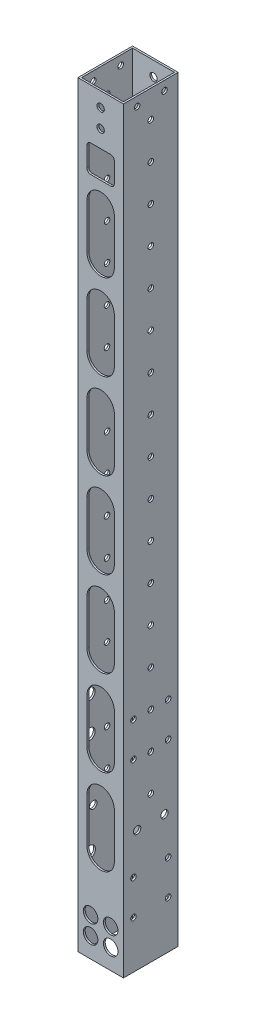
from build123d import *

# Parameters (mm, degrees)
SKETCH_2_W                = 25
SKETCH_2_H                = 30
EXTRUDE_1_DEPTH           = 207.5
SKETCH_3_W                = 23
SKETCH_3_H                = 28
CUT_EXTRUDE_1_DEPTH       = 208.5
CUT_EXTRUDE_1_DEPTH_BACK  = 208.5
SKETCH_4_R                = 1.525
CUT_EXTRUDE_2_DEPTH       = 1
CUT_EXTRUDE_2_DEPTH_BACK  = 26
CUT_EXTRUDE_3_REACH       = 27
SKETCH_5_R                = 3.15
SKETCH_6_R                = 2.025
CUT_EXTRUDE_4_DEPTH       = 31
SKETCH_7_R                = 2.025
CUT_EXTRUDE_5_DEPTH       = 1
CUT_EXTRUDE_5_DEPTH_BACK  = 31
SKETCH_8_R                = 4
CUT_EXTRUDE_6_DEPTH       = 10
SKETCH_9_R                = 1.525
CUT_EXTRUDE_7_DEPTH       = 1
CUT_EXTRUDE_7_DEPTH_BACK  = 26
SKETCH_10_R               = 3
CUT_EXTRUDE_8_DEPTH       = 5
SKETCH_11_R               = 1.525
CUT_EXTRUDE_9_DEPTH       = 26
PATTERN_LINEAR_1_COUNT    = 17
PATTERN_LINEAR_1_PITCH    = 20
SKETCH_13_R               = 1.525
CUT_EXTRUDE_10_DEPTH      = 26
SKETCH_14_R               = 2.025
CUT_EXTRUDE_11_DEPTH      = 1
CUT_EXTRUDE_11_DEPTH_BACK = 26
CUT_EXTRUDE_12_DEPTH      = 5
PATTERN_LINEAR_2_COUNT    = 7
PATTERN_LINEAR_2_PITCH    = 47
CUT_EXTRUDE_13_DEPTH      = 1
CUT_EXTRUDE_13_DEPTH_BACK = 31
CUT_EXTRUDE_14_DEPTH      = 1
CUT_EXTRUDE_14_DEPTH_BACK = 31
CUT_EXTRUDE_15_DEPTH      = 10


with BuildPart() as part:
    # 草图2 → 凸台-拉伸1 (new body, symmetric)
    with BuildSketch(Plane(origin=(0, 0, 0), x_dir=(1, 0, 0), z_dir=(0, 1, 0))):
        Rectangle(SKETCH_2_W, SKETCH_2_H)
    extrude(amount=EXTRUDE_1_DEPTH, both=True)

    # 草图3 → 切除-拉伸1 (cut, two sides)
    with BuildSketch(Plane(origin=(0, 0, 0), x_dir=(1, 0, 0), z_dir=(0, 1, 0))) as cut_extrude_1_sk:
        Rectangle(SKETCH_3_W, SKETCH_3_H)
    extrude(amount=CUT_EXTRUDE_1_DEPTH, mode=Mode.SUBTRACT)
    extrude(cut_extrude_1_sk.sketch, amount=-CUT_EXTRUDE_1_DEPTH_BACK, mode=Mode.SUBTRACT)

    # 草图4 → 切除-拉伸2 (cut, two sides)
    with BuildSketch(Plane.ZY.offset(12.5)) as cut_extrude_2_sk:
        with Locations((-9.5, -162.5)):
            Circle(SKETCH_4_R)
        with Locations((9.5, -162.5)):
            Circle(SKETCH_4_R)
        with Locations((9.5, -181.5)):
            Circle(SKETCH_4_R)
        with Locations((-9.5, -181.5)):
            Circle(SKETCH_4_R)
    extrude(amount=CUT_EXTRUDE_2_DEPTH, mode=Mode.SUBTRACT)
    extrude(cut_extrude_2_sk.sketch, amount=-CUT_EXTRUDE_2_DEPTH_BACK, mode=Mode.SUBTRACT)

    # 草图5 → 切除-拉伸3 (cut, up to next)
    with BuildSketch(Plane.ZY.offset(12.5), mode=Mode.PRIVATE) as cut_extrude_3_sk1:
        with Locations((-9.5, -162.5)):
            Circle(SKETCH_5_R)
    cut_extrude_3_tool1 = extrude(cut_extrude_3_sk1.sketch, amount=-CUT_EXTRUDE_3_REACH, mode=Mode.PRIVATE) & part.part
    add(cut_extrude_3_tool1.solids().sort_by_distance((-12.5, -162.5, -9.5))[0], mode=Mode.SUBTRACT)
    # 草图5 → 切除-拉伸3 (cut, up to next)
    with BuildSketch(Plane.ZY.offset(12.5), mode=Mode.PRIVATE) as cut_extrude_3_sk2:
        with Locations((-9.5, -181.5)):
            Circle(SKETCH_5_R)
    cut_extrude_3_tool2 = extrude(cut_extrude_3_sk2.sketch, amount=-CUT_EXTRUDE_3_REACH, mode=Mode.PRIVATE) & part.part
    add(cut_extrude_3_tool2.solids().sort_by_distance((-12.5, -181.5, -9.5))[0], mode=Mode.SUBTRACT)
    # 草图5 → 切除-拉伸3 (cut, up to next)
    with BuildSketch(Plane.ZY.offset(12.5), mode=Mode.PRIVATE) as cut_extrude_3_sk3:
        with Locations((9.5, -162.5)):
            Circle(SKETCH_5_R)
    cut_extrude_3_tool3 = extrude(cut_extrude_3_sk3.sketch, amount=-CUT_EXTRUDE_3_REACH, mode=Mode.PRIVATE) & part.part
    add(cut_extrude_3_tool3.solids().sort_by_distance((-12.5, -162.5, 9.5))[0], mode=Mode.SUBTRACT)
    # 草图5 → 切除-拉伸3 (cut, up to next)
    with BuildSketch(Plane.ZY.offset(12.5), mode=Mode.PRIVATE) as cut_extrude_3_sk4:
        with Locations((9.5, -181.5)):
            Circle(SKETCH_5_R)
    cut_extrude_3_tool4 = extrude(cut_extrude_3_sk4.sketch, amount=-CUT_EXTRUDE_3_REACH, mode=Mode.PRIVATE) & part.part
    add(cut_extrude_3_tool4.solids().sort_by_distance((-12.5, -181.5, 9.5))[0], mode=Mode.SUBTRACT)

    # 草图6 → 切除-拉伸4 (cut, through all)
    with BuildSketch(Plane(origin=(0, 0, -15), x_dir=(-1, 0, 0), z_dir=(0, 0, -1))):
        with Locations((0, 199.5)):
            Circle(SKETCH_6_R)
        with Locations((0, 189.5)):
            Circle(SKETCH_6_R)
    extrude(amount=-CUT_EXTRUDE_4_DEPTH, mode=Mode.SUBTRACT)

    # 草图7 → 切除-拉伸5 (cut, two sides)
    with BuildSketch(Plane.XY.offset(15)) as cut_extrude_5_sk:
        with Locations((-5.5, -186.5)):
            Circle(SKETCH_7_R)
        with Locations((-5.5, -196.5)):
            Circle(SKETCH_7_R)
        with Locations((5.5, -196.5)):
            Circle(SKETCH_7_R)
        with Locations((5.5, -186.5)):
            Circle(SKETCH_7_R)
    extrude(amount=CUT_EXTRUDE_5_DEPTH, mode=Mode.SUBTRACT)
    extrude(cut_extrude_5_sk.sketch, amount=-CUT_EXTRUDE_5_DEPTH_BACK, mode=Mode.SUBTRACT)

    # 草图8 → 切除-拉伸6 (cut)
    with BuildSketch(Plane.XY.offset(15)):
        with Locations((-5.5, -186.5)):
            Circle(SKETCH_8_R)
        with Locations((5.5, -186.5)):
            Circle(SKETCH_8_R)
        with Locations((5.5, -196.5)):
            Circle(SKETCH_8_R)
        with Locations((-5.5, -196.5)):
            Circle(SKETCH_8_R)
    extrude(amount=-CUT_EXTRUDE_6_DEPTH, mode=Mode.SUBTRACT)

    # 草图9 → 切除-拉伸7 (cut, two sides)
    with BuildSketch(Plane.ZY.offset(12.5)) as cut_extrude_7_sk:
        with Locations((9.5, -106.5)):
            Circle(SKETCH_9_R)
        with Locations((-9.5, -106.5)):
            Circle(SKETCH_9_R)
        with Locations((9.5, -87.5)):
            Circle(SKETCH_9_R)
        with Locations((-9.5, -87.5)):
            Circle(SKETCH_9_R)
    extrude(amount=CUT_EXTRUDE_7_DEPTH, mode=Mode.SUBTRACT)
    extrude(cut_extrude_7_sk.sketch, amount=-CUT_EXTRUDE_7_DEPTH_BACK, mode=Mode.SUBTRACT)

    # 草图10 → 切除-拉伸8 (cut)
    with BuildSketch(Plane.ZY.offset(12.5)):
        with Locations((9.5, -87.5)):
            Circle(SKETCH_10_R)
        with Locations((9.5, -106.5)):
            Circle(SKETCH_10_R)
        with Locations((-9.5, -87.5)):
            Circle(SKETCH_10_R)
        with Locations((-9.5, -106.5)):
            Circle(SKETCH_10_R)
    extrude(amount=-CUT_EXTRUDE_8_DEPTH, mode=Mode.SUBTRACT)

    # 草图11 → 切除-拉伸9 (cut, through all)
    with BuildSketch(Plane.ZY.offset(12.5)):
        with Locations((0, -127.5)):
            Circle(SKETCH_11_R)
    cut_extrude_9 = extrude(amount=-CUT_EXTRUDE_9_DEPTH, mode=Mode.SUBTRACT)

    # 阵列(线性)1: 切除-拉伸9 ×17
    with Locations(*[(0, i * PATTERN_LINEAR_1_PITCH, 0) for i in range(1, PATTERN_LINEAR_1_COUNT)]):
        add(cut_extrude_9, mode=Mode.SUBTRACT)

    # 草图13 → 切除-拉伸10 (cut, through all)
    with BuildSketch(Plane.ZY.offset(12.5)):
        with Locations((7.5, 202.5)):
            Circle(SKETCH_13_R)
        with Locations((-7.5, 202.5)):
            Circle(SKETCH_13_R)
    extrude(amount=-CUT_EXTRUDE_10_DEPTH, mode=Mode.SUBTRACT)

    # 草图14 → 切除-拉伸11 (cut, two sides)
    with BuildSketch(Plane.ZY.offset(12.5)) as cut_extrude_11_sk:
        with Locations((7.5, -141)):
            Circle(SKETCH_14_R)
        with Locations((-7.5, -141)):
            Circle(SKETCH_14_R)
    extrude(amount=CUT_EXTRUDE_11_DEPTH, mode=Mode.SUBTRACT)
    extrude(cut_extrude_11_sk.sketch, amount=-CUT_EXTRUDE_11_DEPTH_BACK, mode=Mode.SUBTRACT)

    # 草图15 → 切除-拉伸12 (cut)
    with BuildSketch(Plane.XY.offset(15)):
        with BuildLine():
            Line((-7.5, -155), (-7.5, -130))
            ThreePointArc((-7.5, -130), (0, -122.5), (7.5, -130))
            Line((7.5, -130), (7.5, -155))
            ThreePointArc((7.5, -155), (0, -162.5), (-7.5, -155))
        make_face()
    cut_extrude_12 = extrude(amount=-CUT_EXTRUDE_12_DEPTH, mode=Mode.SUBTRACT)

    # 阵列(线性)2: 切除-拉伸12 ×7
    with Locations(*[(0, i * PATTERN_LINEAR_2_PITCH, 0) for i in range(1, PATTERN_LINEAR_2_COUNT)]):
        add(cut_extrude_12, mode=Mode.SUBTRACT)

    # 草图17 → 切除-拉伸13 (cut, two sides)
    with BuildSketch(Plane.XY.offset(15)) as cut_extrude_13_sk:
        with BuildLine():
            Line((-5.5, 165), (5.5, 165))
            ThreePointArc((5.5, 165), (6.914213562, 165.585786438), (7.5, 167))
            Line((7.5, 167), (7.5, 178))
            ThreePointArc((7.5, 178), (6.914213562, 179.414213562), (5.5, 180))
            Line((5.5, 180), (-5.5, 180))
            ThreePointArc((-5.5, 180), (-6.914213562, 179.414213562), (-7.5, 178))
            Line((-7.5, 178), (-7.5, 167))
            ThreePointArc((-7.5, 167), (-6.914213562, 165.585786438), (-5.5, 165))
        make_face()
    extrude(amount=CUT_EXTRUDE_13_DEPTH, mode=Mode.SUBTRACT)
    extrude(cut_extrude_13_sk.sketch, amount=-CUT_EXTRUDE_13_DEPTH_BACK, mode=Mode.SUBTRACT)

    # 草图18 → 切除-拉伸14 (cut, two sides)
    with BuildSketch(Plane(origin=(0, 0, -15), x_dir=(-1, 0, 0), z_dir=(0, 0, -1))) as cut_extrude_14_sk:
        with BuildLine():
            Line((-7.5, -155), (-7.5, -130))
            ThreePointArc((-7.5, -130), (0, -122.5), (7.5, -130))
            Line((7.5, -130), (7.5, -155))
            ThreePointArc((7.5, -155), (0, -162.5), (-7.5, -155))
        make_face()
    extrude(amount=CUT_EXTRUDE_14_DEPTH, mode=Mode.SUBTRACT)
    extrude(cut_extrude_14_sk.sketch, amount=-CUT_EXTRUDE_14_DEPTH_BACK, mode=Mode.SUBTRACT)

    # 草图19 → 切除-拉伸15 (cut)
    with BuildSketch(Plane(origin=(0, 0, -15), x_dir=(-1, 0, 0), z_dir=(0, 0, -1))):
        with BuildLine():
            Line((-7, -33), (-7, -23))
            ThreePointArc((-7, -23), (0, -16), (7, -23))
            Line((7, -23), (7, -33))
            ThreePointArc((7, -33), (0, -40), (-7, -33))
        make_face()
        with BuildLine():
            Line((7, -62), (7, -72))
            ThreePointArc((7, -72), (0, -79), (-7, -72))
            Line((-7, -72), (-7, -62))
            ThreePointArc((-7, -62), (0, -55), (7, -62))
        make_face()
        with BuildLine():
            Line((-7, 68), (-7, 78))
            ThreePointArc((-7, 78), (0, 85), (7, 78))
            Line((7, 78), (7, 68))
            ThreePointArc((7, 68), (0, 61), (-7, 68))
        make_face()
        with BuildLine():
            Line((-7, 108), (-7, 118))
            ThreePointArc((-7, 118), (0, 125), (7, 118))
            Line((7, 118), (7, 108))
            ThreePointArc((7, 108), (0, 101), (-7, 108))
        make_face()
    extrude(amount=-CUT_EXTRUDE_15_DEPTH, mode=Mode.SUBTRACT)


solid = part.part
